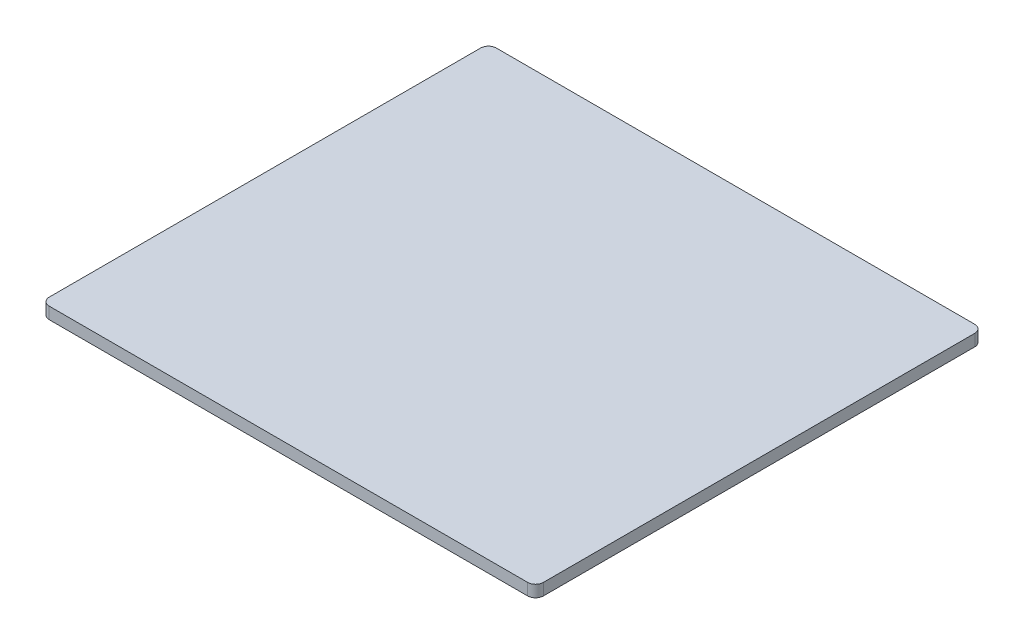
from build123d import *

# Parameters (mm, degrees)
SKETCH1_W           = 63
SKETCH1_H           = 57
BOSS_EXTRUDE1_DEPTH = 1.5
FILLET1_R           = 1
FILLET2_R           = 1
FILLET3_R           = 1


with BuildPart() as part:
    # Sketch1 → Boss-Extrude1 (new body)
    with BuildSketch(Plane(origin=(0, 0, 0), x_dir=(1, 0, 0), z_dir=(0, 1, 0))):
        with Locations((23.995049505, -10.534653465)):
            Rectangle(SKETCH1_W, SKETCH1_H)
    extrude(amount=BOSS_EXTRUDE1_DEPTH)

    # Fillet1
    fillet1_edges = [part.edges().sort_by_distance(p)[0] for p in [
        (55.495049505, 0.75, 39.034653465),
    ]]
    fillet(fillet1_edges, radius=FILLET1_R)

    # Fillet2
    fillet2_edges = [part.edges().sort_by_distance(p)[0] for p in [
        (55.495049505, 0.75, -17.965346535),
    ]]
    fillet(fillet2_edges, radius=FILLET2_R)

    # Fillet3
    fillet3_edges = [part.edges().sort_by_distance(p)[0] for p in [
        (-7.504950495, 0.75, -17.965346535),
        (-7.504950495, 0.75, 39.034653465),
    ]]
    fillet(fillet3_edges, radius=FILLET3_R)


solid = part.part
